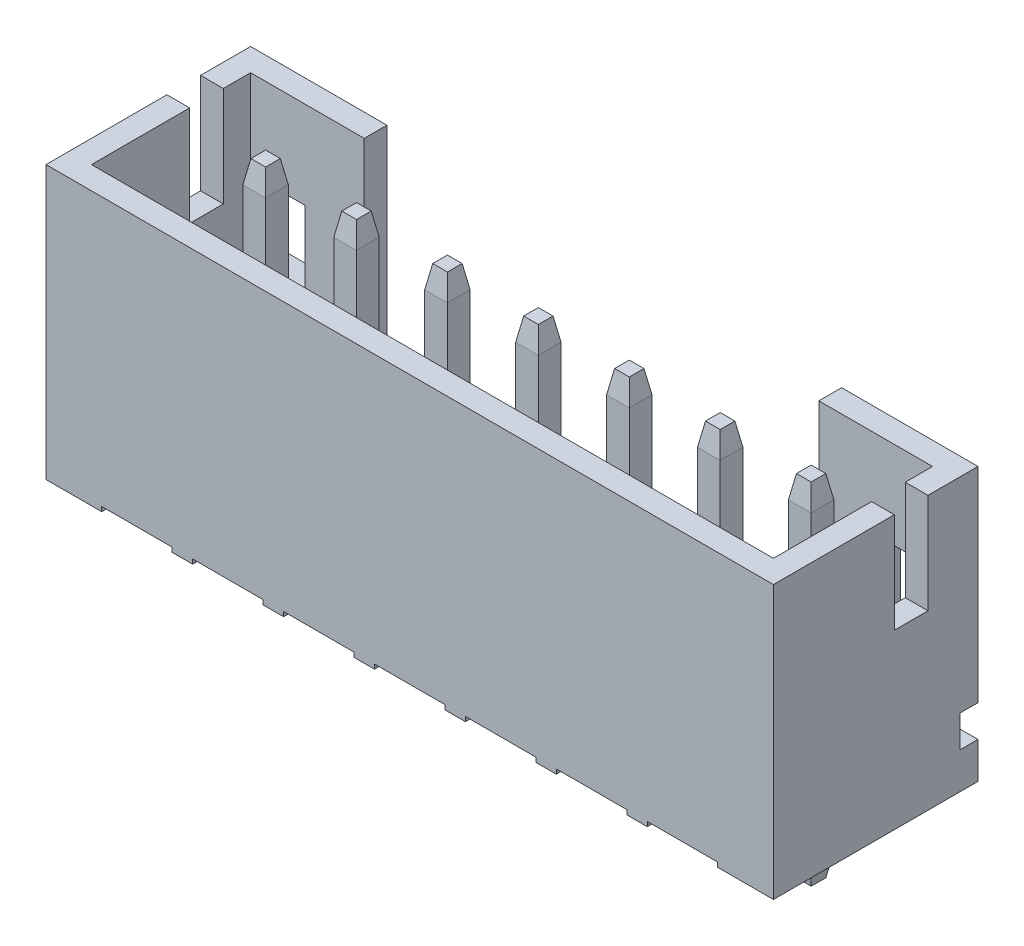
from build123d import *

# Parameters (mm, degrees)
SKETCH1_W               = 16
SKETCH1_H               = 4.5
EXTRUDE1_DEPTH          = 6
CUT_EXTRUDE1_DEPTH      = 5.5
SKETCH3_W               = 15
SKETCH3_H               = 3.5
CUT_EXTRUDE2_DEPTH      = 4.2
SKETCH5_W               = 0.74
SKETCH5_H               = 2.2
CUT_EXTRUDE3_DEPTH      = 17
SKETCH6_W               = 10
SKETCH6_H               = 4
CUT_EXTRUDE4_DEPTH      = 1.2
SKETCH9_W               = 0.4
SKETCH9_H               = 0.7
CUT_EXTRUDE5_DEPTH      = 7
CUT_EXTRUDE5_DEPTH_BACK = 11
SKETCH10_W              = 1.2
SKETCH10_H              = 1.6
CUT_EXTRUDE6_DEPTH      = 0.5
CUT_EXTRUDE7_START      = -9.5
CUT_EXTRUDE7_DEPTH      = 15
LPATTERN4_COUNT         = 3
LPATTERN4_PITCH         = 2
LPATTERN4_COL_COUNT     = 5
LPATTERN4_COL_PITCH     = 2
EXTRUDE2_START          = -2
EXTRUDE2_DEPTH          = 7.7
LPATTERN2_COUNT         = 3
LPATTERN2_PITCH         = 2
LPATTERN2_COL_COUNT     = 5
LPATTERN2_COL_PITCH     = 2
CHAMFER1_SIZE           = 0.5
CHAMFER1_SIZE2          = 0.08816349
CHAMFER1_PART_2_SIZE    = 0.5
CHAMFER1_PART_2_SIZE2   = 0.08816349
CHAMFER1_PART_3_SIZE    = 0.5
CHAMFER1_PART_3_SIZE2   = 0.08816349
CHAMFER1_PART_4_SIZE    = 0.5
CHAMFER1_PART_4_SIZE2   = 0.08816349
CHAMFER1_PART_5_SIZE    = 0.5
CHAMFER1_PART_5_SIZE2   = 0.08816349
CHAMFER1_PART_6_SIZE    = 0.5
CHAMFER1_PART_6_SIZE2   = 0.08816349
CHAMFER1_PART_7_SIZE    = 0.5
CHAMFER1_PART_7_SIZE2   = 0.08816349
CHAMFER1_PART_8_SIZE    = 0.5
CHAMFER1_PART_8_SIZE2   = 0.08816349
CHAMFER1_PART_9_SIZE    = 0.5
CHAMFER1_PART_9_SIZE2   = 0.08816349
CHAMFER1_PART_10_SIZE   = 0.5
CHAMFER1_PART_10_SIZE2  = 0.08816349
CHAMFER1_PART_11_SIZE   = 0.5
CHAMFER1_PART_11_SIZE2  = 0.08816349
CHAMFER1_PART_12_SIZE   = 0.5
CHAMFER1_PART_12_SIZE2  = 0.08816349
CHAMFER1_PART_13_SIZE   = 0.5
CHAMFER1_PART_13_SIZE2  = 0.08816349
CHAMFER1_PART_14_SIZE   = 0.5
CHAMFER1_PART_14_SIZE2  = 0.08816349
CHAMFER1_PART_15_SIZE   = 0.5
CHAMFER1_PART_15_SIZE2  = 0.08816349
CHAMFER1_PART_16_SIZE   = 0.5
CHAMFER1_PART_16_SIZE2  = 0.08816349
CHAMFER1_PART_17_SIZE   = 0.5
CHAMFER1_PART_17_SIZE2  = 0.08816349
CHAMFER1_PART_18_SIZE   = 0.5
CHAMFER1_PART_18_SIZE2  = 0.08816349
CHAMFER1_PART_19_SIZE   = 0.5
CHAMFER1_PART_19_SIZE2  = 0.08816349
CHAMFER1_PART_20_SIZE   = 0.5
CHAMFER1_PART_20_SIZE2  = 0.08816349
CHAMFER1_PART_21_SIZE   = 0.5
CHAMFER1_PART_21_SIZE2  = 0.08816349
CHAMFER1_PART_22_SIZE   = 0.5
CHAMFER1_PART_22_SIZE2  = 0.08816349
CHAMFER1_PART_23_SIZE   = 0.5
CHAMFER1_PART_23_SIZE2  = 0.08816349
CHAMFER1_PART_24_SIZE   = 0.5
CHAMFER1_PART_24_SIZE2  = 0.08816349
CHAMFER1_PART_25_SIZE   = 0.5
CHAMFER1_PART_25_SIZE2  = 0.08816349
CHAMFER1_PART_26_SIZE   = 0.5
CHAMFER1_PART_26_SIZE2  = 0.08816349
CHAMFER1_PART_27_SIZE   = 0.5
CHAMFER1_PART_27_SIZE2  = 0.08816349
CHAMFER1_PART_28_SIZE   = 0.5
CHAMFER1_PART_28_SIZE2  = 0.08816349
CHAMFER1_PART_29_SIZE   = 0.5
CHAMFER1_PART_29_SIZE2  = 0.08816349
CHAMFER1_PART_30_SIZE   = 0.5
CHAMFER1_PART_30_SIZE2  = 0.08816349
CHAMFER1_PART_31_SIZE   = 0.5
CHAMFER1_PART_31_SIZE2  = 0.08816349
CHAMFER1_PART_32_SIZE   = 0.5
CHAMFER1_PART_32_SIZE2  = 0.08816349
CHAMFER1_PART_33_SIZE   = 0.5
CHAMFER1_PART_33_SIZE2  = 0.08816349
CHAMFER1_PART_34_SIZE   = 0.5
CHAMFER1_PART_34_SIZE2  = 0.08816349
CHAMFER1_PART_35_SIZE   = 0.5
CHAMFER1_PART_35_SIZE2  = 0.08816349
CHAMFER1_PART_36_SIZE   = 0.5
CHAMFER1_PART_36_SIZE2  = 0.08816349
CHAMFER1_PART_37_SIZE   = 0.5
CHAMFER1_PART_37_SIZE2  = 0.08816349
CHAMFER1_PART_38_SIZE   = 0.5
CHAMFER1_PART_38_SIZE2  = 0.08816349
CHAMFER1_PART_39_SIZE   = 0.5
CHAMFER1_PART_39_SIZE2  = 0.08816349
CHAMFER1_PART_40_SIZE   = 0.5
CHAMFER1_PART_40_SIZE2  = 0.08816349
CHAMFER1_PART_41_SIZE   = 0.5
CHAMFER1_PART_41_SIZE2  = 0.08816349
CHAMFER1_PART_42_SIZE   = 0.5
CHAMFER1_PART_42_SIZE2  = 0.08816349
CHAMFER1_PART_43_SIZE   = 0.5
CHAMFER1_PART_43_SIZE2  = 0.08816349
CHAMFER1_PART_44_SIZE   = 0.5
CHAMFER1_PART_44_SIZE2  = 0.08816349
CHAMFER1_PART_45_SIZE   = 0.5
CHAMFER1_PART_45_SIZE2  = 0.08816349
CHAMFER1_PART_46_SIZE   = 0.5
CHAMFER1_PART_46_SIZE2  = 0.08816349
CHAMFER1_PART_47_SIZE   = 0.5
CHAMFER1_PART_47_SIZE2  = 0.08816349
CHAMFER1_PART_48_SIZE   = 0.5
CHAMFER1_PART_48_SIZE2  = 0.08816349
CHAMFER1_PART_49_SIZE   = 0.5
CHAMFER1_PART_49_SIZE2  = 0.08816349
CHAMFER1_PART_50_SIZE   = 0.5
CHAMFER1_PART_50_SIZE2  = 0.08816349
CHAMFER1_PART_51_SIZE   = 0.5
CHAMFER1_PART_51_SIZE2  = 0.08816349
CHAMFER1_PART_52_SIZE   = 0.5
CHAMFER1_PART_52_SIZE2  = 0.08816349
CHAMFER1_PART_53_SIZE   = 0.5
CHAMFER1_PART_53_SIZE2  = 0.08816349
CHAMFER1_PART_54_SIZE   = 0.5
CHAMFER1_PART_54_SIZE2  = 0.08816349
CHAMFER1_PART_55_SIZE   = 0.5
CHAMFER1_PART_55_SIZE2  = 0.08816349
CHAMFER1_PART_56_SIZE   = 0.5
CHAMFER1_PART_56_SIZE2  = 0.08816349


with BuildPart() as part:
    # Sketch1 → Extrude1 (new body)
    with BuildSketch(Plane(origin=(0, 0, 0), x_dir=(1, 0, 0), z_dir=(0, 1, 0))):
        with Locations((-2, 0)):
            Rectangle(SKETCH1_W, SKETCH1_H)
    extrude(amount=EXTRUDE1_DEPTH)

    # Sketch2 → Cut-Extrude1 (cut, through all)
    with BuildSketch(Plane.XY.offset(2.25)):
        Polygon((-0.775, 0.1), (0.775, 0.1), (0.775, 0), (0, 0), (-0.775, 0), align=None)
    cut_extrude1 = extrude(amount=-CUT_EXTRUDE1_DEPTH, mode=Mode.SUBTRACT)

    # Sketch3 → Cut-Extrude2 (cut)
    with BuildSketch(Plane(origin=(0, 6, 0), x_dir=(-1, 0, 0), z_dir=(0, 1, 0))):
        with Locations((2, 0)):
            Rectangle(SKETCH3_W, SKETCH3_H)
    extrude(amount=-CUT_EXTRUDE2_DEPTH, mode=Mode.SUBTRACT)

    # Sketch5 → Cut-Extrude3 (cut, through all)
    with BuildSketch(Plane.ZY.offset(10)):
        with Locations((-0.78, 4.9)):
            Rectangle(SKETCH5_W, SKETCH5_H)
    extrude(amount=-CUT_EXTRUDE3_DEPTH, mode=Mode.SUBTRACT)

    # Sketch6 → Cut-Extrude4 (cut)
    with BuildSketch(Plane(origin=(0, 0, -2.25), x_dir=(-1, 0, 0), z_dir=(0, 0, -1))):
        with Locations((2, 4)):
            Rectangle(SKETCH6_W, SKETCH6_H)
    extrude(amount=-CUT_EXTRUDE4_DEPTH, mode=Mode.SUBTRACT)

    # Sketch9 → Cut-Extrude5 (cut, two sides)
    with BuildSketch(Plane(origin=(0, 0, 0), x_dir=(0, 0, -1), z_dir=(1, 0, 0))) as cut_extrude5_sk:
        with Locations((2.05, 1.15)):
            Rectangle(SKETCH9_W, SKETCH9_H)
    extrude(amount=CUT_EXTRUDE5_DEPTH, mode=Mode.SUBTRACT)
    extrude(cut_extrude5_sk.sketch, amount=-CUT_EXTRUDE5_DEPTH_BACK, mode=Mode.SUBTRACT)

    # Sketch10 → Cut-Extrude6 (cut)
    with BuildSketch(Plane(origin=(0, 0, -2.25), x_dir=(-1, 0, 0), z_dir=(0, 0, -1))):
        with Locations((-4.9, 3.271645398)):
            Rectangle(SKETCH10_W, SKETCH10_H)
        with Locations((8.9, 3.271645398)):
            Rectangle(SKETCH10_W, SKETCH10_H)
    extrude(amount=-CUT_EXTRUDE6_DEPTH, mode=Mode.SUBTRACT)

    # Sketch11 → Cut-Extrude7 (cut)
    with BuildSketch(Plane(origin=(0, 0, 0), x_dir=(0, 0, -1), z_dir=(1, 0, 0)).offset(CUT_EXTRUDE7_START)):
        Polygon((0, 1.8), (-0.576387184, 1.223612816), (-1.75, 1.223612816), (-1.75, 1.8), align=None)
    extrude(amount=CUT_EXTRUDE7_DEPTH, mode=Mode.SUBTRACT)

    # LPattern4: Cut-Extrude1 ×3
    with Locations(*[(i * LPATTERN4_PITCH, 0, 0) for i in range(1, LPATTERN4_COUNT)]):
        add(cut_extrude1, mode=Mode.SUBTRACT)

    # LPattern4 col: Cut-Extrude1 ×5
    with Locations(*[(-i * LPATTERN4_COL_PITCH, 0, 0) for i in range(1, LPATTERN4_COL_COUNT)]):
        add(cut_extrude1, mode=Mode.SUBTRACT)

    # Sketch7 → Extrude2 (add)
    with BuildSketch(Plane(origin=(0, 0, 0), x_dir=(1, 0, 0), z_dir=(0, 1, 0)).offset(EXTRUDE2_START)):
        Polygon((0, 0.33), (0.25, 0.33), (0.25, 0.83), (-0.25, 0.83), (-0.25, 0.33), align=None)
    extrude2 = extrude(amount=EXTRUDE2_DEPTH)

    # LPattern2: Extrude2 ×3
    with Locations(*[(i * LPATTERN2_PITCH, 0, 0) for i in range(1, LPATTERN2_COUNT)]):
        add(extrude2)

    # LPattern2 col: Extrude2 ×5
    with Locations(*[(-i * LPATTERN2_COL_PITCH, 0, 0) for i in range(1, LPATTERN2_COL_COUNT)]):
        add(extrude2)

    # Chamfer1
    chamfer1_edges = [part.edges().sort_by_distance(p)[0] for p in [
        (-0.25, -2, -0.58),
    ]]
    chamfer1_side = [part.faces().sort_by_distance(p)[0] for p in [
        (-0.25, -0.95, -0.58),
    ]]
    chamfer(chamfer1_edges, length=CHAMFER1_SIZE, length2=CHAMFER1_SIZE2, reference=chamfer1_side[0])

    # Chamfer1 part 2
    chamfer1_part_2_edges = [part.edges().sort_by_distance(p)[0] for p in [
        (0, -2, -0.33),
    ]]
    chamfer1_part_2_side = [part.faces().sort_by_distance(p)[0] for p in [
        (0, -0.95, -0.33),
    ]]
    chamfer(chamfer1_part_2_edges, length=CHAMFER1_PART_2_SIZE, length2=CHAMFER1_PART_2_SIZE2, reference=chamfer1_part_2_side[0])

    # Chamfer1 part 3
    chamfer1_part_3_edges = [part.edges().sort_by_distance(p)[0] for p in [
        (0.25, -2, -0.58),
    ]]
    chamfer1_part_3_side = [part.faces().sort_by_distance(p)[0] for p in [
        (0.25, -0.95, -0.58),
    ]]
    chamfer(chamfer1_part_3_edges, length=CHAMFER1_PART_3_SIZE, length2=CHAMFER1_PART_3_SIZE2, reference=chamfer1_part_3_side[0])

    # Chamfer1 part 4
    chamfer1_part_4_edges = [part.edges().sort_by_distance(p)[0] for p in [
        (0, -2, -0.83),
    ]]
    chamfer1_part_4_side = [part.faces().sort_by_distance(p)[0] for p in [
        (0, -0.95, -0.83),
    ]]
    chamfer(chamfer1_part_4_edges, length=CHAMFER1_PART_4_SIZE, length2=CHAMFER1_PART_4_SIZE2, reference=chamfer1_part_4_side[0])

    # Chamfer1 part 5
    chamfer1_part_5_edges = [part.edges().sort_by_distance(p)[0] for p in [
        (0, 5.7, -0.83),
    ]]
    chamfer1_part_5_side = [part.faces().sort_by_distance(p)[0] for p in [
        (0, 3.75, -0.83),
    ]]
    chamfer(chamfer1_part_5_edges, length=CHAMFER1_PART_5_SIZE, length2=CHAMFER1_PART_5_SIZE2, reference=chamfer1_part_5_side[0])

    # Chamfer1 part 6
    chamfer1_part_6_edges = [part.edges().sort_by_distance(p)[0] for p in [
        (-0.25, 5.7, -0.58),
    ]]
    chamfer1_part_6_side = [part.faces().sort_by_distance(p)[0] for p in [
        (-0.25, 3.75, -0.58),
    ]]
    chamfer(chamfer1_part_6_edges, length=CHAMFER1_PART_6_SIZE, length2=CHAMFER1_PART_6_SIZE2, reference=chamfer1_part_6_side[0])

    # Chamfer1 part 7
    chamfer1_part_7_edges = [part.edges().sort_by_distance(p)[0] for p in [
        (0, 5.7, -0.33),
    ]]
    chamfer1_part_7_side = [part.faces().sort_by_distance(p)[0] for p in [
        (0, 3.75, -0.33),
    ]]
    chamfer(chamfer1_part_7_edges, length=CHAMFER1_PART_7_SIZE, length2=CHAMFER1_PART_7_SIZE2, reference=chamfer1_part_7_side[0])

    # Chamfer1 part 8
    chamfer1_part_8_edges = [part.edges().sort_by_distance(p)[0] for p in [
        (0.25, 5.7, -0.58),
    ]]
    chamfer1_part_8_side = [part.faces().sort_by_distance(p)[0] for p in [
        (0.25, 3.75, -0.58),
    ]]
    chamfer(chamfer1_part_8_edges, length=CHAMFER1_PART_8_SIZE, length2=CHAMFER1_PART_8_SIZE2, reference=chamfer1_part_8_side[0])

    # Chamfer1 part 9
    chamfer1_part_9_edges = [part.edges().sort_by_distance(p)[0] for p in [
        (-2.25, -2, -0.58),
    ]]
    chamfer1_part_9_side = [part.faces().sort_by_distance(p)[0] for p in [
        (-2.25, -0.95, -0.58),
    ]]
    chamfer(chamfer1_part_9_edges, length=CHAMFER1_PART_9_SIZE, length2=CHAMFER1_PART_9_SIZE2, reference=chamfer1_part_9_side[0])

    # Chamfer1 part 10
    chamfer1_part_10_edges = [part.edges().sort_by_distance(p)[0] for p in [
        (-2, -2, -0.33),
    ]]
    chamfer1_part_10_side = [part.faces().sort_by_distance(p)[0] for p in [
        (-2, -0.95, -0.33),
    ]]
    chamfer(chamfer1_part_10_edges, length=CHAMFER1_PART_10_SIZE, length2=CHAMFER1_PART_10_SIZE2, reference=chamfer1_part_10_side[0])

    # Chamfer1 part 11
    chamfer1_part_11_edges = [part.edges().sort_by_distance(p)[0] for p in [
        (-1.75, -2, -0.58),
    ]]
    chamfer1_part_11_side = [part.faces().sort_by_distance(p)[0] for p in [
        (-1.75, -0.95, -0.58),
    ]]
    chamfer(chamfer1_part_11_edges, length=CHAMFER1_PART_11_SIZE, length2=CHAMFER1_PART_11_SIZE2, reference=chamfer1_part_11_side[0])

    # Chamfer1 part 12
    chamfer1_part_12_edges = [part.edges().sort_by_distance(p)[0] for p in [
        (-2, -2, -0.83),
    ]]
    chamfer1_part_12_side = [part.faces().sort_by_distance(p)[0] for p in [
        (-2, -0.95, -0.83),
    ]]
    chamfer(chamfer1_part_12_edges, length=CHAMFER1_PART_12_SIZE, length2=CHAMFER1_PART_12_SIZE2, reference=chamfer1_part_12_side[0])

    # Chamfer1 part 13
    chamfer1_part_13_edges = [part.edges().sort_by_distance(p)[0] for p in [
        (-2, 5.7, -0.83),
    ]]
    chamfer1_part_13_side = [part.faces().sort_by_distance(p)[0] for p in [
        (-2, 3.75, -0.83),
    ]]
    chamfer(chamfer1_part_13_edges, length=CHAMFER1_PART_13_SIZE, length2=CHAMFER1_PART_13_SIZE2, reference=chamfer1_part_13_side[0])

    # Chamfer1 part 14
    chamfer1_part_14_edges = [part.edges().sort_by_distance(p)[0] for p in [
        (-2.25, 5.7, -0.58),
    ]]
    chamfer1_part_14_side = [part.faces().sort_by_distance(p)[0] for p in [
        (-2.25, 3.75, -0.58),
    ]]
    chamfer(chamfer1_part_14_edges, length=CHAMFER1_PART_14_SIZE, length2=CHAMFER1_PART_14_SIZE2, reference=chamfer1_part_14_side[0])

    # Chamfer1 part 15
    chamfer1_part_15_edges = [part.edges().sort_by_distance(p)[0] for p in [
        (-2, 5.7, -0.33),
    ]]
    chamfer1_part_15_side = [part.faces().sort_by_distance(p)[0] for p in [
        (-2, 3.75, -0.33),
    ]]
    chamfer(chamfer1_part_15_edges, length=CHAMFER1_PART_15_SIZE, length2=CHAMFER1_PART_15_SIZE2, reference=chamfer1_part_15_side[0])

    # Chamfer1 part 16
    chamfer1_part_16_edges = [part.edges().sort_by_distance(p)[0] for p in [
        (-1.75, 5.7, -0.58),
    ]]
    chamfer1_part_16_side = [part.faces().sort_by_distance(p)[0] for p in [
        (-1.75, 3.75, -0.58),
    ]]
    chamfer(chamfer1_part_16_edges, length=CHAMFER1_PART_16_SIZE, length2=CHAMFER1_PART_16_SIZE2, reference=chamfer1_part_16_side[0])

    # Chamfer1 part 17
    chamfer1_part_17_edges = [part.edges().sort_by_distance(p)[0] for p in [
        (-4.25, -2, -0.58),
    ]]
    chamfer1_part_17_side = [part.faces().sort_by_distance(p)[0] for p in [
        (-4.25, -0.95, -0.58),
    ]]
    chamfer(chamfer1_part_17_edges, length=CHAMFER1_PART_17_SIZE, length2=CHAMFER1_PART_17_SIZE2, reference=chamfer1_part_17_side[0])

    # Chamfer1 part 18
    chamfer1_part_18_edges = [part.edges().sort_by_distance(p)[0] for p in [
        (-4, -2, -0.33),
    ]]
    chamfer1_part_18_side = [part.faces().sort_by_distance(p)[0] for p in [
        (-4, -0.95, -0.33),
    ]]
    chamfer(chamfer1_part_18_edges, length=CHAMFER1_PART_18_SIZE, length2=CHAMFER1_PART_18_SIZE2, reference=chamfer1_part_18_side[0])

    # Chamfer1 part 19
    chamfer1_part_19_edges = [part.edges().sort_by_distance(p)[0] for p in [
        (-3.75, -2, -0.58),
    ]]
    chamfer1_part_19_side = [part.faces().sort_by_distance(p)[0] for p in [
        (-3.75, -0.95, -0.58),
    ]]
    chamfer(chamfer1_part_19_edges, length=CHAMFER1_PART_19_SIZE, length2=CHAMFER1_PART_19_SIZE2, reference=chamfer1_part_19_side[0])

    # Chamfer1 part 20
    chamfer1_part_20_edges = [part.edges().sort_by_distance(p)[0] for p in [
        (-4, -2, -0.83),
    ]]
    chamfer1_part_20_side = [part.faces().sort_by_distance(p)[0] for p in [
        (-4, -0.95, -0.83),
    ]]
    chamfer(chamfer1_part_20_edges, length=CHAMFER1_PART_20_SIZE, length2=CHAMFER1_PART_20_SIZE2, reference=chamfer1_part_20_side[0])

    # Chamfer1 part 21
    chamfer1_part_21_edges = [part.edges().sort_by_distance(p)[0] for p in [
        (-4, 5.7, -0.83),
    ]]
    chamfer1_part_21_side = [part.faces().sort_by_distance(p)[0] for p in [
        (-4, 3.75, -0.83),
    ]]
    chamfer(chamfer1_part_21_edges, length=CHAMFER1_PART_21_SIZE, length2=CHAMFER1_PART_21_SIZE2, reference=chamfer1_part_21_side[0])

    # Chamfer1 part 22
    chamfer1_part_22_edges = [part.edges().sort_by_distance(p)[0] for p in [
        (-4.25, 5.7, -0.58),
    ]]
    chamfer1_part_22_side = [part.faces().sort_by_distance(p)[0] for p in [
        (-4.25, 3.75, -0.58),
    ]]
    chamfer(chamfer1_part_22_edges, length=CHAMFER1_PART_22_SIZE, length2=CHAMFER1_PART_22_SIZE2, reference=chamfer1_part_22_side[0])

    # Chamfer1 part 23
    chamfer1_part_23_edges = [part.edges().sort_by_distance(p)[0] for p in [
        (-4, 5.7, -0.33),
    ]]
    chamfer1_part_23_side = [part.faces().sort_by_distance(p)[0] for p in [
        (-4, 3.75, -0.33),
    ]]
    chamfer(chamfer1_part_23_edges, length=CHAMFER1_PART_23_SIZE, length2=CHAMFER1_PART_23_SIZE2, reference=chamfer1_part_23_side[0])

    # Chamfer1 part 24
    chamfer1_part_24_edges = [part.edges().sort_by_distance(p)[0] for p in [
        (-3.75, 5.7, -0.58),
    ]]
    chamfer1_part_24_side = [part.faces().sort_by_distance(p)[0] for p in [
        (-3.75, 3.75, -0.58),
    ]]
    chamfer(chamfer1_part_24_edges, length=CHAMFER1_PART_24_SIZE, length2=CHAMFER1_PART_24_SIZE2, reference=chamfer1_part_24_side[0])

    # Chamfer1 part 25
    chamfer1_part_25_edges = [part.edges().sort_by_distance(p)[0] for p in [
        (-6.25, -2, -0.58),
    ]]
    chamfer1_part_25_side = [part.faces().sort_by_distance(p)[0] for p in [
        (-6.25, -0.95, -0.58),
    ]]
    chamfer(chamfer1_part_25_edges, length=CHAMFER1_PART_25_SIZE, length2=CHAMFER1_PART_25_SIZE2, reference=chamfer1_part_25_side[0])

    # Chamfer1 part 26
    chamfer1_part_26_edges = [part.edges().sort_by_distance(p)[0] for p in [
        (-6, -2, -0.33),
    ]]
    chamfer1_part_26_side = [part.faces().sort_by_distance(p)[0] for p in [
        (-6, -0.95, -0.33),
    ]]
    chamfer(chamfer1_part_26_edges, length=CHAMFER1_PART_26_SIZE, length2=CHAMFER1_PART_26_SIZE2, reference=chamfer1_part_26_side[0])

    # Chamfer1 part 27
    chamfer1_part_27_edges = [part.edges().sort_by_distance(p)[0] for p in [
        (-5.75, -2, -0.58),
    ]]
    chamfer1_part_27_side = [part.faces().sort_by_distance(p)[0] for p in [
        (-5.75, -0.95, -0.58),
    ]]
    chamfer(chamfer1_part_27_edges, length=CHAMFER1_PART_27_SIZE, length2=CHAMFER1_PART_27_SIZE2, reference=chamfer1_part_27_side[0])

    # Chamfer1 part 28
    chamfer1_part_28_edges = [part.edges().sort_by_distance(p)[0] for p in [
        (-6, -2, -0.83),
    ]]
    chamfer1_part_28_side = [part.faces().sort_by_distance(p)[0] for p in [
        (-6, -0.95, -0.83),
    ]]
    chamfer(chamfer1_part_28_edges, length=CHAMFER1_PART_28_SIZE, length2=CHAMFER1_PART_28_SIZE2, reference=chamfer1_part_28_side[0])

    # Chamfer1 part 29
    chamfer1_part_29_edges = [part.edges().sort_by_distance(p)[0] for p in [
        (-6, 5.7, -0.83),
    ]]
    chamfer1_part_29_side = [part.faces().sort_by_distance(p)[0] for p in [
        (-6, 3.75, -0.83),
    ]]
    chamfer(chamfer1_part_29_edges, length=CHAMFER1_PART_29_SIZE, length2=CHAMFER1_PART_29_SIZE2, reference=chamfer1_part_29_side[0])

    # Chamfer1 part 30
    chamfer1_part_30_edges = [part.edges().sort_by_distance(p)[0] for p in [
        (-6.25, 5.7, -0.58),
    ]]
    chamfer1_part_30_side = [part.faces().sort_by_distance(p)[0] for p in [
        (-6.25, 3.75, -0.58),
    ]]
    chamfer(chamfer1_part_30_edges, length=CHAMFER1_PART_30_SIZE, length2=CHAMFER1_PART_30_SIZE2, reference=chamfer1_part_30_side[0])

    # Chamfer1 part 31
    chamfer1_part_31_edges = [part.edges().sort_by_distance(p)[0] for p in [
        (-6, 5.7, -0.33),
    ]]
    chamfer1_part_31_side = [part.faces().sort_by_distance(p)[0] for p in [
        (-6, 3.75, -0.33),
    ]]
    chamfer(chamfer1_part_31_edges, length=CHAMFER1_PART_31_SIZE, length2=CHAMFER1_PART_31_SIZE2, reference=chamfer1_part_31_side[0])

    # Chamfer1 part 32
    chamfer1_part_32_edges = [part.edges().sort_by_distance(p)[0] for p in [
        (-5.75, 5.7, -0.58),
    ]]
    chamfer1_part_32_side = [part.faces().sort_by_distance(p)[0] for p in [
        (-5.75, 3.75, -0.58),
    ]]
    chamfer(chamfer1_part_32_edges, length=CHAMFER1_PART_32_SIZE, length2=CHAMFER1_PART_32_SIZE2, reference=chamfer1_part_32_side[0])

    # Chamfer1 part 33
    chamfer1_part_33_edges = [part.edges().sort_by_distance(p)[0] for p in [
        (-8.25, -2, -0.58),
    ]]
    chamfer1_part_33_side = [part.faces().sort_by_distance(p)[0] for p in [
        (-8.25, -0.95, -0.58),
    ]]
    chamfer(chamfer1_part_33_edges, length=CHAMFER1_PART_33_SIZE, length2=CHAMFER1_PART_33_SIZE2, reference=chamfer1_part_33_side[0])

    # Chamfer1 part 34
    chamfer1_part_34_edges = [part.edges().sort_by_distance(p)[0] for p in [
        (-8, -2, -0.33),
    ]]
    chamfer1_part_34_side = [part.faces().sort_by_distance(p)[0] for p in [
        (-8, -0.95, -0.33),
    ]]
    chamfer(chamfer1_part_34_edges, length=CHAMFER1_PART_34_SIZE, length2=CHAMFER1_PART_34_SIZE2, reference=chamfer1_part_34_side[0])

    # Chamfer1 part 35
    chamfer1_part_35_edges = [part.edges().sort_by_distance(p)[0] for p in [
        (-7.75, -2, -0.58),
    ]]
    chamfer1_part_35_side = [part.faces().sort_by_distance(p)[0] for p in [
        (-7.75, -0.95, -0.58),
    ]]
    chamfer(chamfer1_part_35_edges, length=CHAMFER1_PART_35_SIZE, length2=CHAMFER1_PART_35_SIZE2, reference=chamfer1_part_35_side[0])

    # Chamfer1 part 36
    chamfer1_part_36_edges = [part.edges().sort_by_distance(p)[0] for p in [
        (-8, -2, -0.83),
    ]]
    chamfer1_part_36_side = [part.faces().sort_by_distance(p)[0] for p in [
        (-8, -0.95, -0.83),
    ]]
    chamfer(chamfer1_part_36_edges, length=CHAMFER1_PART_36_SIZE, length2=CHAMFER1_PART_36_SIZE2, reference=chamfer1_part_36_side[0])

    # Chamfer1 part 37
    chamfer1_part_37_edges = [part.edges().sort_by_distance(p)[0] for p in [
        (-8, 5.7, -0.83),
    ]]
    chamfer1_part_37_side = [part.faces().sort_by_distance(p)[0] for p in [
        (-8, 3.75, -0.83),
    ]]
    chamfer(chamfer1_part_37_edges, length=CHAMFER1_PART_37_SIZE, length2=CHAMFER1_PART_37_SIZE2, reference=chamfer1_part_37_side[0])

    # Chamfer1 part 38
    chamfer1_part_38_edges = [part.edges().sort_by_distance(p)[0] for p in [
        (-8.25, 5.7, -0.58),
    ]]
    chamfer1_part_38_side = [part.faces().sort_by_distance(p)[0] for p in [
        (-8.25, 3.75, -0.58),
    ]]
    chamfer(chamfer1_part_38_edges, length=CHAMFER1_PART_38_SIZE, length2=CHAMFER1_PART_38_SIZE2, reference=chamfer1_part_38_side[0])

    # Chamfer1 part 39
    chamfer1_part_39_edges = [part.edges().sort_by_distance(p)[0] for p in [
        (-8, 5.7, -0.33),
    ]]
    chamfer1_part_39_side = [part.faces().sort_by_distance(p)[0] for p in [
        (-8, 3.75, -0.33),
    ]]
    chamfer(chamfer1_part_39_edges, length=CHAMFER1_PART_39_SIZE, length2=CHAMFER1_PART_39_SIZE2, reference=chamfer1_part_39_side[0])

    # Chamfer1 part 40
    chamfer1_part_40_edges = [part.edges().sort_by_distance(p)[0] for p in [
        (-7.75, 5.7, -0.58),
    ]]
    chamfer1_part_40_side = [part.faces().sort_by_distance(p)[0] for p in [
        (-7.75, 3.75, -0.58),
    ]]
    chamfer(chamfer1_part_40_edges, length=CHAMFER1_PART_40_SIZE, length2=CHAMFER1_PART_40_SIZE2, reference=chamfer1_part_40_side[0])

    # Chamfer1 part 41
    chamfer1_part_41_edges = [part.edges().sort_by_distance(p)[0] for p in [
        (1.75, -2, -0.58),
    ]]
    chamfer1_part_41_side = [part.faces().sort_by_distance(p)[0] for p in [
        (1.75, -0.95, -0.58),
    ]]
    chamfer(chamfer1_part_41_edges, length=CHAMFER1_PART_41_SIZE, length2=CHAMFER1_PART_41_SIZE2, reference=chamfer1_part_41_side[0])

    # Chamfer1 part 42
    chamfer1_part_42_edges = [part.edges().sort_by_distance(p)[0] for p in [
        (2, -2, -0.33),
    ]]
    chamfer1_part_42_side = [part.faces().sort_by_distance(p)[0] for p in [
        (2, -0.95, -0.33),
    ]]
    chamfer(chamfer1_part_42_edges, length=CHAMFER1_PART_42_SIZE, length2=CHAMFER1_PART_42_SIZE2, reference=chamfer1_part_42_side[0])

    # Chamfer1 part 43
    chamfer1_part_43_edges = [part.edges().sort_by_distance(p)[0] for p in [
        (2.25, -2, -0.58),
    ]]
    chamfer1_part_43_side = [part.faces().sort_by_distance(p)[0] for p in [
        (2.25, -0.95, -0.58),
    ]]
    chamfer(chamfer1_part_43_edges, length=CHAMFER1_PART_43_SIZE, length2=CHAMFER1_PART_43_SIZE2, reference=chamfer1_part_43_side[0])

    # Chamfer1 part 44
    chamfer1_part_44_edges = [part.edges().sort_by_distance(p)[0] for p in [
        (2, -2, -0.83),
    ]]
    chamfer1_part_44_side = [part.faces().sort_by_distance(p)[0] for p in [
        (2, -0.95, -0.83),
    ]]
    chamfer(chamfer1_part_44_edges, length=CHAMFER1_PART_44_SIZE, length2=CHAMFER1_PART_44_SIZE2, reference=chamfer1_part_44_side[0])

    # Chamfer1 part 45
    chamfer1_part_45_edges = [part.edges().sort_by_distance(p)[0] for p in [
        (2, 5.7, -0.83),
    ]]
    chamfer1_part_45_side = [part.faces().sort_by_distance(p)[0] for p in [
        (2, 3.75, -0.83),
    ]]
    chamfer(chamfer1_part_45_edges, length=CHAMFER1_PART_45_SIZE, length2=CHAMFER1_PART_45_SIZE2, reference=chamfer1_part_45_side[0])

    # Chamfer1 part 46
    chamfer1_part_46_edges = [part.edges().sort_by_distance(p)[0] for p in [
        (1.75, 5.7, -0.58),
    ]]
    chamfer1_part_46_side = [part.faces().sort_by_distance(p)[0] for p in [
        (1.75, 3.75, -0.58),
    ]]
    chamfer(chamfer1_part_46_edges, length=CHAMFER1_PART_46_SIZE, length2=CHAMFER1_PART_46_SIZE2, reference=chamfer1_part_46_side[0])

    # Chamfer1 part 47
    chamfer1_part_47_edges = [part.edges().sort_by_distance(p)[0] for p in [
        (2, 5.7, -0.33),
    ]]
    chamfer1_part_47_side = [part.faces().sort_by_distance(p)[0] for p in [
        (2, 3.75, -0.33),
    ]]
    chamfer(chamfer1_part_47_edges, length=CHAMFER1_PART_47_SIZE, length2=CHAMFER1_PART_47_SIZE2, reference=chamfer1_part_47_side[0])

    # Chamfer1 part 48
    chamfer1_part_48_edges = [part.edges().sort_by_distance(p)[0] for p in [
        (2.25, 5.7, -0.58),
    ]]
    chamfer1_part_48_side = [part.faces().sort_by_distance(p)[0] for p in [
        (2.25, 3.75, -0.58),
    ]]
    chamfer(chamfer1_part_48_edges, length=CHAMFER1_PART_48_SIZE, length2=CHAMFER1_PART_48_SIZE2, reference=chamfer1_part_48_side[0])

    # Chamfer1 part 49
    chamfer1_part_49_edges = [part.edges().sort_by_distance(p)[0] for p in [
        (3.75, -2, -0.58),
    ]]
    chamfer1_part_49_side = [part.faces().sort_by_distance(p)[0] for p in [
        (3.75, -0.95, -0.58),
    ]]
    chamfer(chamfer1_part_49_edges, length=CHAMFER1_PART_49_SIZE, length2=CHAMFER1_PART_49_SIZE2, reference=chamfer1_part_49_side[0])

    # Chamfer1 part 50
    chamfer1_part_50_edges = [part.edges().sort_by_distance(p)[0] for p in [
        (4, -2, -0.33),
    ]]
    chamfer1_part_50_side = [part.faces().sort_by_distance(p)[0] for p in [
        (4, -0.95, -0.33),
    ]]
    chamfer(chamfer1_part_50_edges, length=CHAMFER1_PART_50_SIZE, length2=CHAMFER1_PART_50_SIZE2, reference=chamfer1_part_50_side[0])

    # Chamfer1 part 51
    chamfer1_part_51_edges = [part.edges().sort_by_distance(p)[0] for p in [
        (4.25, -2, -0.58),
    ]]
    chamfer1_part_51_side = [part.faces().sort_by_distance(p)[0] for p in [
        (4.25, -0.95, -0.58),
    ]]
    chamfer(chamfer1_part_51_edges, length=CHAMFER1_PART_51_SIZE, length2=CHAMFER1_PART_51_SIZE2, reference=chamfer1_part_51_side[0])

    # Chamfer1 part 52
    chamfer1_part_52_edges = [part.edges().sort_by_distance(p)[0] for p in [
        (4, -2, -0.83),
    ]]
    chamfer1_part_52_side = [part.faces().sort_by_distance(p)[0] for p in [
        (4, -0.95, -0.83),
    ]]
    chamfer(chamfer1_part_52_edges, length=CHAMFER1_PART_52_SIZE, length2=CHAMFER1_PART_52_SIZE2, reference=chamfer1_part_52_side[0])

    # Chamfer1 part 53
    chamfer1_part_53_edges = [part.edges().sort_by_distance(p)[0] for p in [
        (4, 5.7, -0.83),
    ]]
    chamfer1_part_53_side = [part.faces().sort_by_distance(p)[0] for p in [
        (4, 3.75, -0.83),
    ]]
    chamfer(chamfer1_part_53_edges, length=CHAMFER1_PART_53_SIZE, length2=CHAMFER1_PART_53_SIZE2, reference=chamfer1_part_53_side[0])

    # Chamfer1 part 54
    chamfer1_part_54_edges = [part.edges().sort_by_distance(p)[0] for p in [
        (3.75, 5.7, -0.58),
    ]]
    chamfer1_part_54_side = [part.faces().sort_by_distance(p)[0] for p in [
        (3.75, 3.75, -0.58),
    ]]
    chamfer(chamfer1_part_54_edges, length=CHAMFER1_PART_54_SIZE, length2=CHAMFER1_PART_54_SIZE2, reference=chamfer1_part_54_side[0])

    # Chamfer1 part 55
    chamfer1_part_55_edges = [part.edges().sort_by_distance(p)[0] for p in [
        (4, 5.7, -0.33),
    ]]
    chamfer1_part_55_side = [part.faces().sort_by_distance(p)[0] for p in [
        (4, 3.75, -0.33),
    ]]
    chamfer(chamfer1_part_55_edges, length=CHAMFER1_PART_55_SIZE, length2=CHAMFER1_PART_55_SIZE2, reference=chamfer1_part_55_side[0])

    # Chamfer1 part 56
    chamfer1_part_56_edges = [part.edges().sort_by_distance(p)[0] for p in [
        (4.25, 5.7, -0.58),
    ]]
    chamfer1_part_56_side = [part.faces().sort_by_distance(p)[0] for p in [
        (4.25, 3.75, -0.58),
    ]]
    chamfer(chamfer1_part_56_edges, length=CHAMFER1_PART_56_SIZE, length2=CHAMFER1_PART_56_SIZE2, reference=chamfer1_part_56_side[0])


solid = part.part
